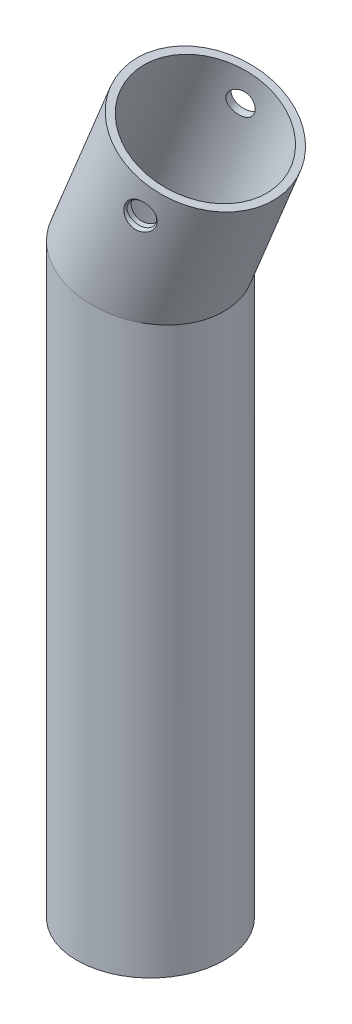
from build123d import *

# Parameters (mm, degrees)
SKETCH_1_R          = 10
SKETCH_1_R_2        = 9
M4X0_71_D           = 3.3
M4X0_71_CSINK_D     = 4.05
M4X0_71_CSINK_ANGLE = 90


with BuildPart() as part:
    # По траектории2: sweep along a path in Эскиз2
    with BuildLine(Plane.XY) as sweep_2_path:
        Line((0, 0), (0, 78.426510273))
        Line((0, 78.426510273), (7.471377296, 96.690895762))
    # Эскиз1 → По траектории2 (sweep)
    with BuildSketch(Plane(origin=(0, 0, 0), x_dir=(1, 0, 0), z_dir=(0, 1, 0))):
        Circle(SKETCH_1_R)
        Circle(SKETCH_1_R_2, mode=Mode.SUBTRACT)
    sweep(path=sweep_2_path.line, transition=Transition.RIGHT)

    # Отверстие обработанное метчиком M4x0.71 (through all)
    with Locations(Plane(origin=(8.205564009, 91.642912959, 9.658566578), x_dir=(0.970537064, 0, -0.240951879), z_dir=(0.23978989, -0.098090393, 0.965856658))):
        with Locations((0, 0)):
            CounterSinkHole(M4X0_71_D / 2, M4X0_71_CSINK_D / 2, counter_sink_angle=M4X0_71_CSINK_ANGLE)


solid = part.part
